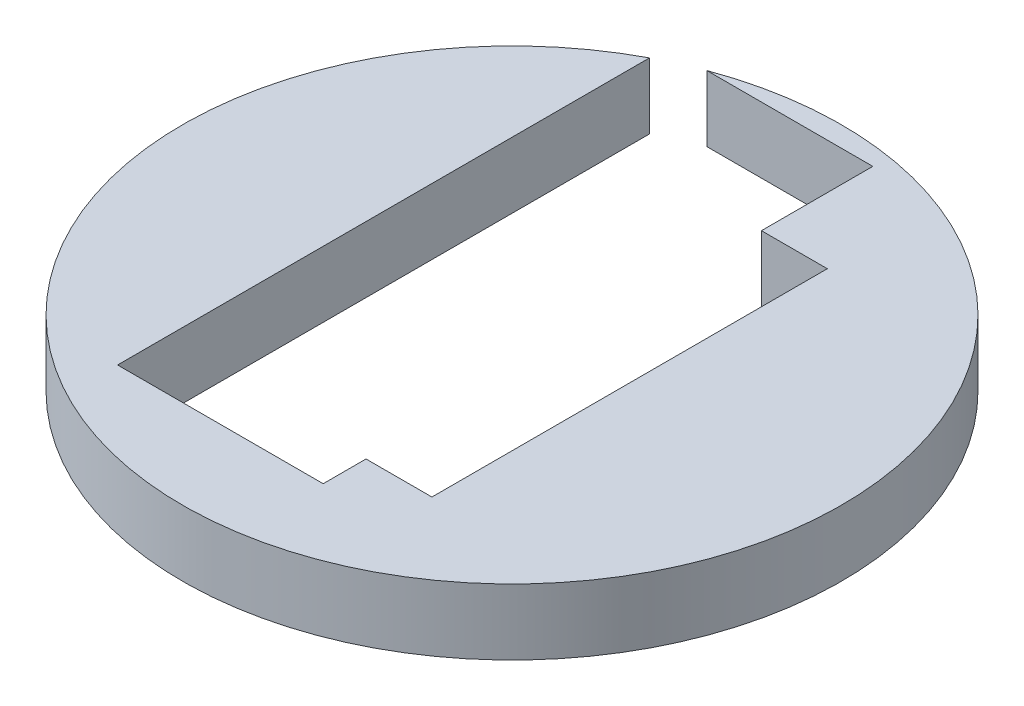
from build123d import *

# Parameters (mm, degrees)
SKETCH1_R           = 47.625
BOSS_EXTRUDE1_DEPTH = 12.7
SKETCH2_R           = 47.625
BOSS_EXTRUDE4_DEPTH = 12.7
BOSS_EXTRUDE5_DEPTH = 4.7625
SKETCH14_W          = 19.812
SKETCH14_H          = 52.959
CUT_EXTRUDE11_DEPTH = 9.275815586
BOSS_EXTRUDE7_DEPTH = 6.35


with BuildPart() as part:
    # Sketch1 → Boss-Extrude1 (new body)
    with BuildSketch(Plane(origin=(0, 0, 0), x_dir=(1, 0, 0), z_dir=(0, 1, 0))):
        Circle(SKETCH1_R)
    extrude(amount=-BOSS_EXTRUDE1_DEPTH)

    # Sketch14 → Cut-Extrude11 (cut)
    with BuildSketch(Plane.XZ.offset(12.7)):
        with Locations((-4.92125, -3.302)):
            Rectangle(SKETCH14_W, SKETCH14_H)
    extrude(amount=-CUT_EXTRUDE11_DEPTH, mode=Mode.SUBTRACT)


with BuildPart() as body_2:
    # Sketch2 → Boss-Extrude4 (new body)
    with BuildSketch(Plane(origin=(0, 0, 0), x_dir=(1, 0, 0), z_dir=(0, 1, 0))):
        Circle(SKETCH2_R)
        with BuildLine():
            Line((30.48, 5.08), (26.035, 5.08))
            Line((26.035, 5.08), (26.035, -36.027507199))
            ThreePointArc((26.035, -36.027507199), (0, -44.45), (-26.035, -36.027507199))
            Line((-26.035, -36.027507199), (-26.035, 5.08))
            Line((-26.035, 5.08), (-30.48, 5.08))
            Line((-30.48, 5.08), (-30.48, -32.353857575))
            ThreePointArc((-30.48, -32.353857575), (-43.961440483, 6.572233308), (-19.685, 39.853522743))
            Line((-19.685, 39.853522743), (-19.685, 25.0825))
            Line((-19.685, 25.0825), (-15.24, 25.0825))
            Line((-15.24, 25.0825), (-15.24, 41.755776846))
            ThreePointArc((-15.24, 41.755776846), (0, 44.45), (15.24, 41.755776846))
            Line((15.24, 41.755776846), (15.24, 25.0825))
            Line((15.24, 25.0825), (19.685, 25.0825))
            Line((19.685, 25.0825), (19.685, 39.853522743))
            ThreePointArc((19.685, 39.853522743), (43.961440483, 6.572233308), (30.48, -32.353857575))
            Line((30.48, -32.353857575), (30.48, 5.08))
        make_face(mode=Mode.SUBTRACT)
    extrude(amount=BOSS_EXTRUDE4_DEPTH)


with BuildPart() as body_3:
    # Sketch10 → Boss-Extrude5 (new body)
    with BuildSketch(Plane(origin=(0, 0, 0), x_dir=(1, 0, 0), z_dir=(0, 1, 0))):
        with BuildLine():
            ThreePointArc((4.7625, -44.19412963), (7.475442585, -43.816894666), (10.16, -43.273281595))
            Line((10.16, -43.273281595), (10.16, 43.273281595))
            ThreePointArc((10.16, 43.273281595), (7.475442585, 43.816894666), (4.7625, 44.19412963))
            Line((4.7625, 44.19412963), (4.7625, -44.19412963))
        make_face()
    extrude(amount=BOSS_EXTRUDE5_DEPTH)


with BuildPart() as body_4:
    # Sketch18 → Boss-Extrude7 (new body)
    with BuildSketch(Plane.XZ.offset(12.7)):
        with BuildLine():
            Line((-14.82725, 23.1775), (4.98475, 23.1775))
            Line((4.98475, 23.1775), (4.98475, 19.05))
            Line((4.98475, 19.05), (11.33475, 19.05))
            Line((11.33475, 19.05), (11.33475, -19.05))
            Line((11.33475, -19.05), (4.98475, -19.05))
            Line((4.98475, -19.05), (4.98475, -29.7815))
            Line((4.98475, -29.7815), (-11.005669346, -29.7815))
            ThreePointArc((-11.005669346, -29.7815), (12.944605873, 28.991372489), (-14.82725, -28.075169767))
            Line((-14.82725, -28.075169767), (-14.82725, 23.1775))
        make_face()
    extrude(amount=BOSS_EXTRUDE7_DEPTH)


solid = body_4.part
